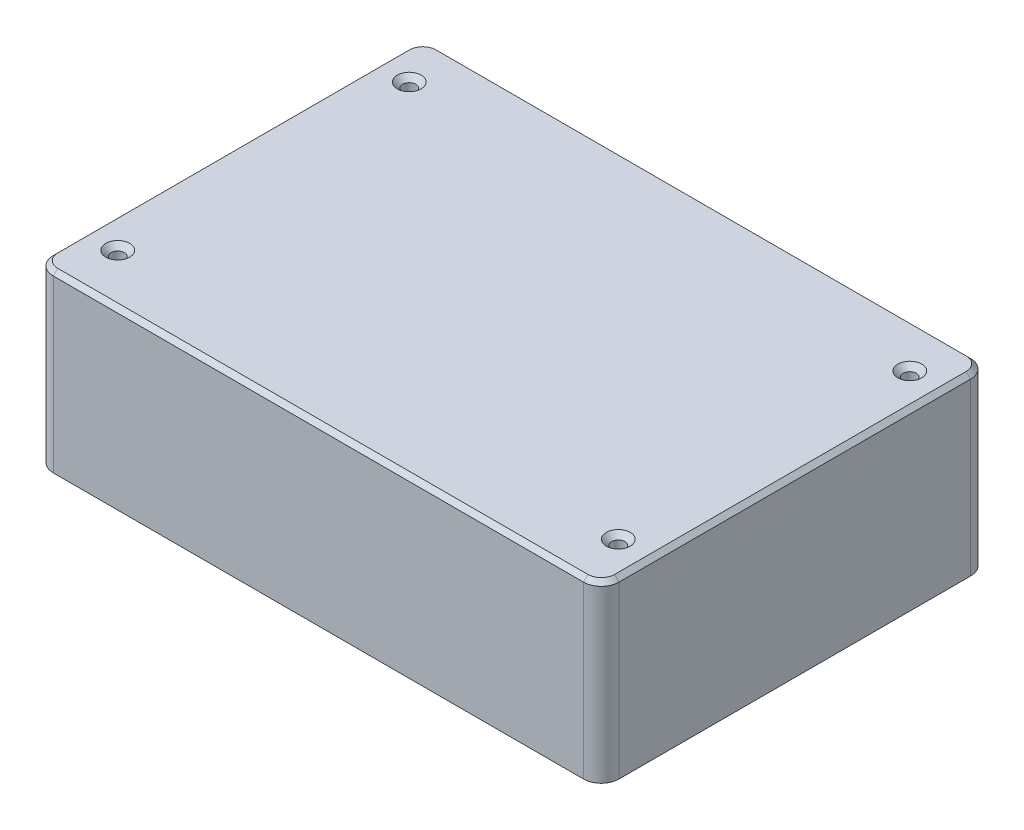
from build123d import *

# Parameters (mm, degrees)
SKETCH1_W                                       = 127.7
SKETCH1_H                                       = 87.4
BOSS_EXTRUDE1_DEPTH                             = 39.5
SHELL1_T                                        = -3
FILLET2_R                                       = 4
CSK_FOR_M2_FLAT_HEAD_MACHINE_SCREW3_D           = 3
CSK_FOR_M2_FLAT_HEAD_MACHINE_SCREW3_CSINK_D     = 5.4
CSK_FOR_M2_FLAT_HEAD_MACHINE_SCREW3_CSINK_ANGLE = 90
CUT_EXTRUDE1_REACH                              = 89.4
CHAMFER1_SIZE                                   = 1
CHAMFER2_SIZE                                   = 1
CHAMFER3_SIZE                                   = 1


with BuildPart() as part:
    # Sketch1 → Boss-Extrude1 (new body)
    with BuildSketch(Plane(origin=(0, 0, 0), x_dir=(1, 0, 0), z_dir=(0, 1, 0))):
        Rectangle(SKETCH1_W, SKETCH1_H)
    extrude(amount=BOSS_EXTRUDE1_DEPTH)

    # Shell1
    shell1_openings = [part.faces().sort_by_distance(p)[0] for p in [
        (0, 0, 0),
    ]]
    offset(amount=SHELL1_T, openings=shell1_openings, kind=Kind.INTERSECTION)

    # Fillet2
    fillet2_edges = [part.edges().sort_by_distance(p)[0] for p in [
        (-63.85, 19.75, -43.7),
        (63.85, 19.75, -43.7),
        (63.85, 19.75, 43.7),
        (-63.85, 19.75, 43.7),
    ]]
    fillet(fillet2_edges, radius=FILLET2_R)

    # CSK for M2 Flat Head Machine Screw3 (through all)
    with Locations(Plane(origin=(56.4, 39.5, -33.4), x_dir=(0, 0, 1), z_dir=(0, 1, 0))):
        with Locations((0, 0), (0, -113), (65.8, -113), (65.8, 0)):
            CounterSinkHole(CSK_FOR_M2_FLAT_HEAD_MACHINE_SCREW3_D / 2, CSK_FOR_M2_FLAT_HEAD_MACHINE_SCREW3_CSINK_D / 2, counter_sink_angle=CSK_FOR_M2_FLAT_HEAD_MACHINE_SCREW3_CSINK_ANGLE)

    # Sketch9 → Cut-Extrude1 (cut, up to next)
    with BuildSketch(Plane(origin=(0, 0, -43.7), x_dir=(-1, 0, 0), z_dir=(0, 0, -1)), mode=Mode.PRIVATE) as cut_extrude1_sk1:
        with BuildLine():
            Line((-27.2, 22.11), (-22.5, 22.11))
            ThreePointArc((-22.5, 22.11), (-18.75, 18.36), (-22.5, 14.61))
            Line((-22.5, 14.61), (-27.2, 14.61))
            ThreePointArc((-27.2, 14.61), (-30.95, 18.36), (-27.2, 22.11))
        make_face()
    cut_extrude1_tool1 = extrude(cut_extrude1_sk1.sketch, amount=-CUT_EXTRUDE1_REACH, mode=Mode.PRIVATE) & part.part
    add(cut_extrude1_tool1.solids().sort_by_distance((24.85, 18.36, -43.7))[0], mode=Mode.SUBTRACT)

    # Chamfer1
    chamfer1_edges = [part.edges().sort_by_distance(p)[0] for p in [
        (30.95, 18.36, -43.7),
        (24.85, 14.61, -43.7),
        (18.75, 18.36, -43.7),
        (24.85, 22.11, -43.7),
        (24.85, 14.61, -40.7),
        (18.75, 18.36, -40.7),
        (24.85, 22.11, -40.7),
        (30.95, 18.36, -40.7),
    ]]
    chamfer(chamfer1_edges, length=CHAMFER1_SIZE)

    # Chamfer2
    chamfer2_edges = [part.edges().sort_by_distance(p)[0] for p in [
        (0, 39.5, -43.7),
        (63.85, 39.5, 0),
        (-63.85, 39.5, 0),
        (0, 39.5, 43.7),
        (62.678427125, 39.5, 42.528427125),
        (-62.678427125, 39.5, 42.528427125),
        (-62.678427125, 39.5, -42.528427125),
        (62.678427125, 39.5, -42.528427125),
    ]]
    chamfer(chamfer2_edges, length=CHAMFER2_SIZE)

    # Chamfer3
    chamfer3_edges = [part.edges().sort_by_distance(p)[0] for p in [
        (-60.85, 18.25, -40.7),
        (-60.85, 18.25, 40.7),
        (60.85, 18.25, 40.7),
        (60.85, 18.25, -40.7),
        (-60.85, 36.5, 0),
        (0, 36.5, 40.7),
        (60.85, 36.5, 0),
        (0, 36.5, -40.7),
    ]]
    chamfer(chamfer3_edges, length=CHAMFER3_SIZE)


solid = part.part
